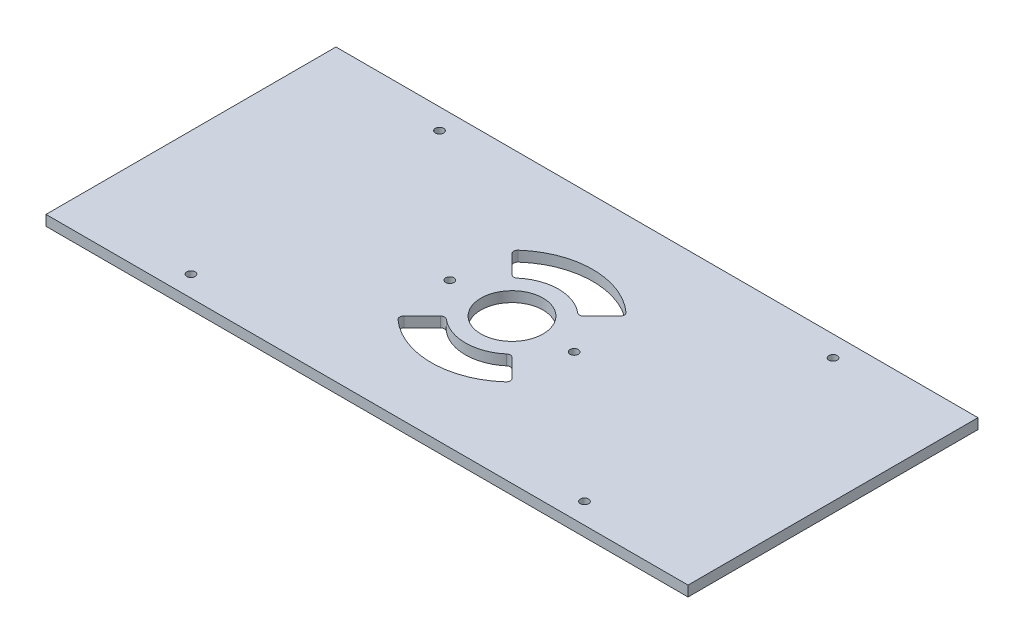
from build123d import *

# Parameters (mm, degrees)
SKETCH2_W           = 310
SKETCH2_H           = 140
BOSS_EXTRUDE1_DEPTH = 5
SKETCH3_R           = 15
CUT_EXTRUDE1_DEPTH  = 6
SKETCH5_R           = 2
CUT_EXTRUDE2_DEPTH  = 6
CUT_EXTRUDE3_DEPTH  = 10
FILLET1_R           = 2
SKETCH7_R           = 2
CUT_EXTRUDE4_DEPTH  = 6


with BuildPart() as part:
    # Sketch2 → Boss-Extrude1 (new body)
    with BuildSketch(Plane(origin=(0, 0, 0), x_dir=(1, 0, 0), z_dir=(0, 1, 0))):
        Rectangle(SKETCH2_W, SKETCH2_H)
    extrude(amount=BOSS_EXTRUDE1_DEPTH)

    # Sketch3 → Cut-Extrude1 (cut, through all)
    with BuildSketch(Plane(origin=(0, 5, 0), x_dir=(1, 0, 0), z_dir=(0, 1, 0))):
        Circle(SKETCH3_R)
    extrude(amount=-CUT_EXTRUDE1_DEPTH, mode=Mode.SUBTRACT)

    # Sketch5 → Cut-Extrude2 (cut, through all)
    with BuildSketch(Plane(origin=(0, 5, 0), x_dir=(1, 0, 0), z_dir=(0, 1, 0))):
        with Locations((-95, 60)):
            Circle(SKETCH5_R)
        with Locations((95, 60)):
            Circle(SKETCH5_R)
        with Locations((95, -60)):
            Circle(SKETCH5_R)
        with Locations((-95, -60)):
            Circle(SKETCH5_R)
    extrude(amount=-CUT_EXTRUDE2_DEPTH, mode=Mode.SUBTRACT)

    # Sketch6 → Cut-Extrude3 (cut)
    with BuildSketch(Plane(origin=(0, 5, 0), x_dir=(1, 0, 0), z_dir=(0, 1, 0))):
        with BuildLine():
            Line((27.577164466, -27.577164466), (15.909902577, -15.909902577))
            ThreePointArc((15.909902577, -15.909902577), (0, -22.5), (-15.909902577, -15.909902577))
            Line((-15.909902577, -15.909902577), (-27.577164466, -27.577164466))
            ThreePointArc((-27.577164466, -27.577164466), (0, -39), (27.577164466, -27.577164466))
        make_face()
        with BuildLine():
            ThreePointArc((-15.909902577, 15.909902577), (0, 22.5), (15.909902577, 15.909902577))
            Line((15.909902577, 15.909902577), (27.577164466, 27.577164466))
            ThreePointArc((27.577164466, 27.577164466), (0, 39), (-27.577164466, 27.577164466))
            Line((-27.577164466, 27.577164466), (-15.909902577, 15.909902577))
        make_face()
    extrude(amount=-CUT_EXTRUDE3_DEPTH, mode=Mode.SUBTRACT)

    # Fillet1
    fillet1_edges = [part.edges().sort_by_distance(p)[0] for p in [
        (-15.909902577, 2.5, 15.909902577),
        (15.909902577, 2.5, 15.909902577),
        (27.577164466, 2.5, 27.577164466),
        (-27.577164466, 2.5, 27.577164466),
        (15.909902577, 2.5, -15.909902577),
        (-15.909902577, 2.5, -15.909902577),
        (-27.577164466, 2.5, -27.577164466),
        (27.577164466, 2.5, -27.577164466),
    ]]
    fillet(fillet1_edges, radius=FILLET1_R)

    # Sketch7 → Cut-Extrude4 (cut, through all)
    with BuildSketch(Plane(origin=(0, 5, 0), x_dir=(1, 0, 0), z_dir=(0, 1, 0))):
        with Locations((-30, 0)):
            Circle(SKETCH7_R)
        with Locations((30, 0)):
            Circle(SKETCH7_R)
    extrude(amount=-CUT_EXTRUDE4_DEPTH, mode=Mode.SUBTRACT)


solid = part.part
